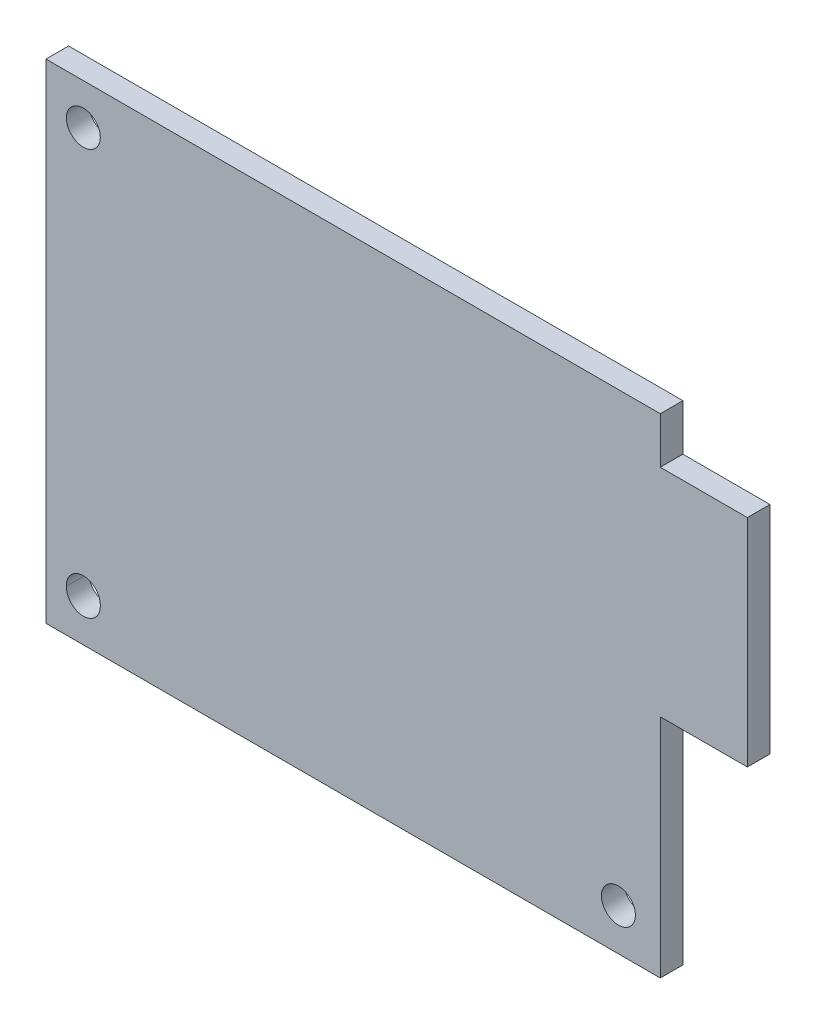
from build123d import *

# Parameters (mm, degrees)
BOSS_EXTRU_1_DEPTH     = 2
D_GAGEMENT_M3_51_D     = 3
D_GAGEMENT_M3_51_DEPTH = 2


with BuildPart() as part:
    # Esquisse1 → Boss.-Extru.1 (new body)
    with BuildSketch(Plane.XY):
        Polygon((27.15, 17.5), (34.85, 17.5), (34.85, -1.6), (27.15, -1.6), (27.15, -21.6), (-27.15, -21.6), (-27.15, 21.6), (27.15, 21.6), align=None)
    extrude(amount=BOSS_EXTRU_1_DEPTH)

    # Dégagement M3.51
    with Locations(Plane.XY.offset(2)):
        with Locations((-23.85, 18), (-23.85, -17.9), (-23.85, -17.8), (23.45, -17.9)):
            Hole(D_GAGEMENT_M3_51_D / 2, depth=D_GAGEMENT_M3_51_DEPTH)


solid = part.part
